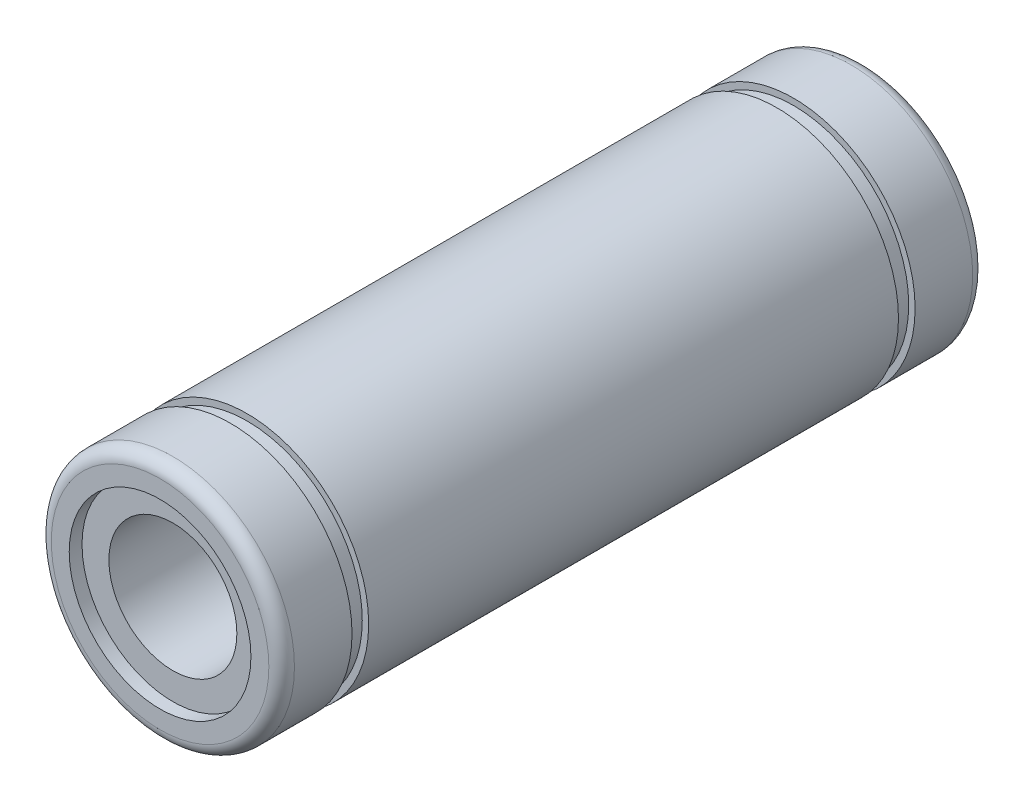
from build123d import *

# Parameters (mm, degrees)
SKETCH1_R           = 9.5
SKETCH1_R_2         = 5
BOSS_EXTRUDE1_DEPTH = 55
SKETCH2_R           = 7.1
CUT_EXTRUDE1_DEPTH  = 1
SKETCH3_R           = 7.1
CUT_EXTRUDE2_DEPTH  = 1
SKETCH4_W           = 0.5
SKETCH4_H           = 1.3
FILLET1_R           = 1


with BuildPart() as part:
    # Sketch1 → Boss-Extrude1 (new body)
    with BuildSketch(Plane.XY):
        Circle(SKETCH1_R)
        Circle(SKETCH1_R_2, mode=Mode.SUBTRACT)
    extrude(amount=BOSS_EXTRUDE1_DEPTH)

    # Sketch2 → Cut-Extrude1 (cut)
    with BuildSketch(Plane.XY.offset(55)):
        Circle(SKETCH2_R)
    extrude(amount=-CUT_EXTRUDE1_DEPTH, mode=Mode.SUBTRACT)

    # Sketch3 → Cut-Extrude2 (cut)
    with BuildSketch(Plane(origin=(0, 0, 0), x_dir=(-1, 0, 0), z_dir=(0, 0, -1))):
        Circle(SKETCH3_R)
    extrude(amount=-CUT_EXTRUDE2_DEPTH, mode=Mode.SUBTRACT)

    # Sketch4 → Cut-Revolve1 (revolve, cut)
    with BuildSketch(Plane(origin=(0, 0, 0), x_dir=(1, 0, 0), z_dir=(0, 1, 0))):
        with Locations((-9.25, -48.85)):
            Rectangle(SKETCH4_W, SKETCH4_H)
        with Locations((-9.25, -6.15)):
            Rectangle(SKETCH4_W, SKETCH4_H)
    revolve(axis=Axis((0, 0, 0), (0, 0, 1)), mode=Mode.SUBTRACT)

    # Fillet1
    fillet1_edges = [part.edges().sort_by_distance(p)[0] for p in [
        (-9.5, 0, 0),
        (-9.5, 0, 55),
    ]]
    fillet(fillet1_edges, radius=FILLET1_R)


solid = part.part
